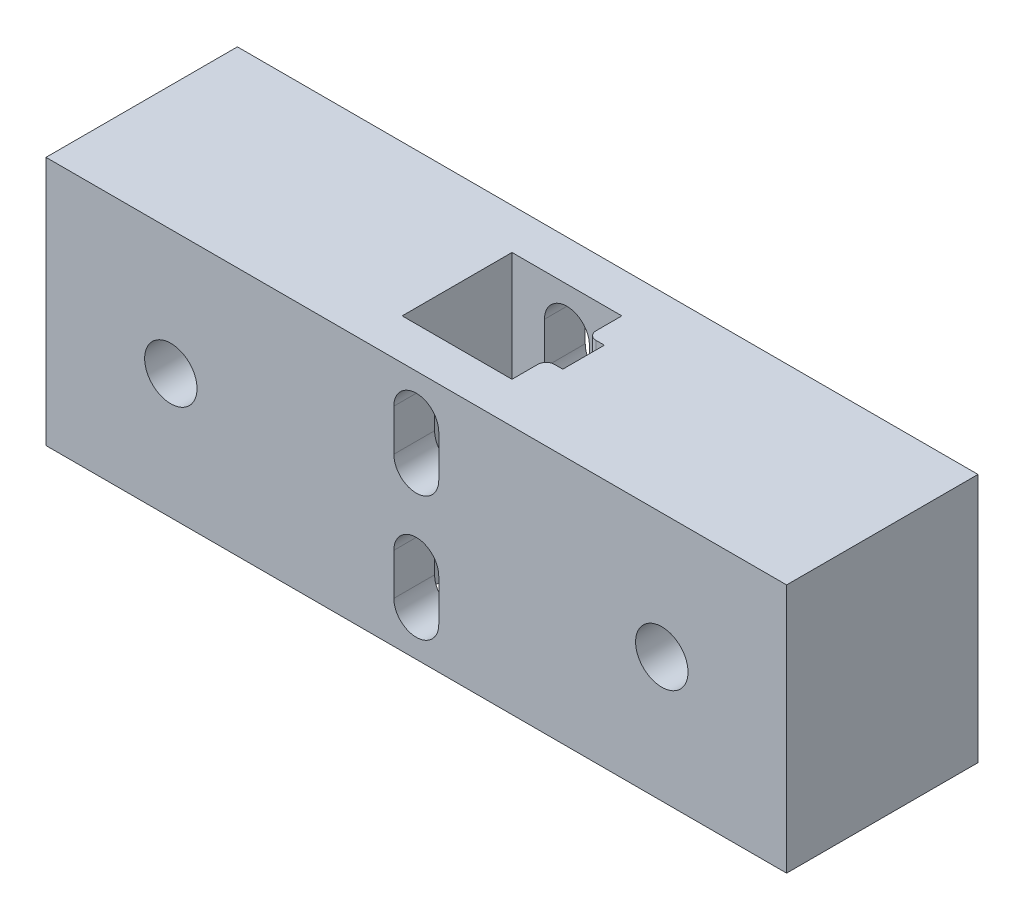
from build123d import *

# Parameters (mm, degrees)
ESQUISSE1_W             = 89
ESQUISSE1_H             = 30
BOSS_EXTRU_1_DEPTH      = 23
ESQUISSE2_W             = 13.2
ESQUISSE2_H             = 13.2
ESQUISSE2_W_2           = 2
ESQUISSE2_H_2           = 5
ENL_V_MAT_EXTRU_1_DEPTH = 31
ESQUISSE3_R             = 3.15
ENL_V_MAT_EXTRU_2_DEPTH = 24
ENL_V_MAT_EXTRU_3_DEPTH = 24
CONG_1_R                = 1


with BuildPart() as part:
    # Esquisse1 → Boss.-Extru.1 (new body)
    with BuildSketch(Plane.XY):
        with Locations((40.389968792, -13.091136671)):
            Rectangle(ESQUISSE1_W, ESQUISSE1_H)
    extrude(amount=BOSS_EXTRU_1_DEPTH)

    # Esquisse2 → Enlèv. mat.-Extru.1 (cut, through all)
    with BuildSketch(Plane(origin=(0, 1.908863329, 0), x_dir=(1, 0, 0), z_dir=(0, 1, 0))):
        with Locations((40.389968792, -11.5)):
            Rectangle(ESQUISSE2_W, ESQUISSE2_H)
        with Locations((47.989968792, -11.5)):
            Rectangle(ESQUISSE2_W_2, ESQUISSE2_H_2)
    extrude(amount=-ENL_V_MAT_EXTRU_1_DEPTH, mode=Mode.SUBTRACT)

    # Esquisse3 → Enlèv. mat.-Extru.2 (cut, through all)
    with BuildSketch(Plane(origin=(0, 0, 0), x_dir=(-1, 0, 0), z_dir=(0, 0, -1))):
        with Locations((-10.889968792, -13.091136671)):
            Circle(ESQUISSE3_R)
        with Locations((-69.889968792, -13.091136671)):
            Circle(ESQUISSE3_R)
    extrude(amount=-ENL_V_MAT_EXTRU_2_DEPTH, mode=Mode.SUBTRACT)

    # Esquisse4 → Enlèv. mat.-Extru.3 (cut, through all)
    with BuildSketch(Plane(origin=(0, 0, 0), x_dir=(-1, 0, 0), z_dir=(0, 0, -1))):
        with BuildLine():
            ThreePointArc((-37.689968792, -8.091136671), (-40.389968792, -10.791136671), (-43.089968792, -8.091136671))
            Line((-43.089968792, -8.091136671), (-43.089968792, -3.091136671))
            ThreePointArc((-43.089968792, -3.091136671), (-40.389968792, -0.391136671), (-37.689968792, -3.091136671))
            Line((-37.689968792, -3.091136671), (-37.689968792, -8.091136671))
        make_face()
        with BuildLine():
            Line((-43.089968792, -23.091136671), (-43.089968792, -18.091136671))
            ThreePointArc((-43.089968792, -18.091136671), (-40.389968792, -15.391136671), (-37.689968792, -18.091136671))
            Line((-37.689968792, -18.091136671), (-37.689968792, -23.091136671))
            ThreePointArc((-37.689968792, -23.091136671), (-40.389968792, -25.791136671), (-43.089968792, -23.091136671))
        make_face()
    extrude(amount=-ENL_V_MAT_EXTRU_3_DEPTH, mode=Mode.SUBTRACT)

    # Congé1
    cong_1_edges = [part.edges().sort_by_distance(p)[0] for p in [
        (46.989968792, -13.091136671, 9),
        (46.989968792, -13.091136671, 14),
    ]]
    fillet(cong_1_edges, radius=CONG_1_R)


solid = part.part
